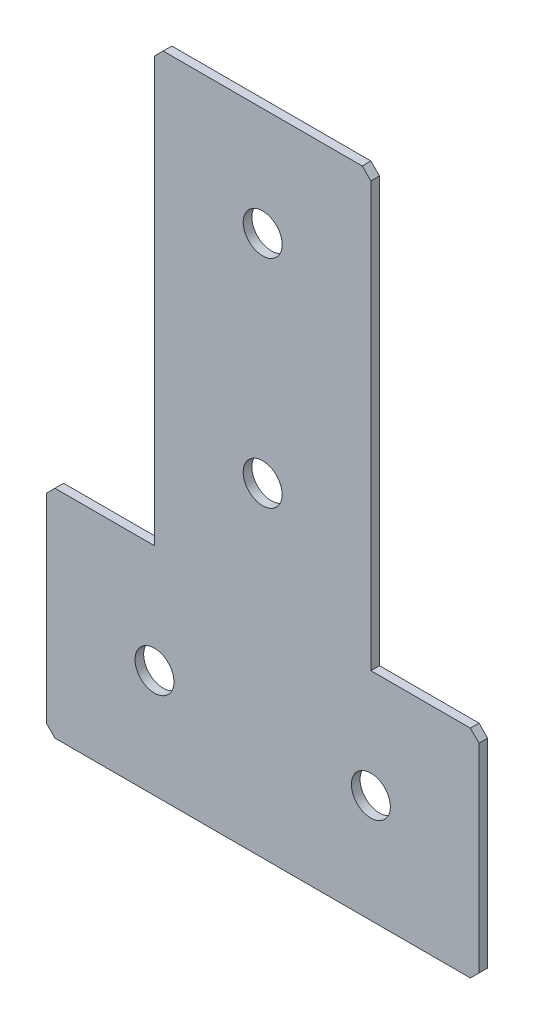
from build123d import *

# Parameters (mm, degrees)
EXTRUDE_1_DEPTH   = 2
HOLE_WIZARD_M81_D = 9
CHAMFER_1_SIZE    = 2


with BuildPart() as part:
    # Эскиз1 → Бобышка-Вытянуть1 (new body)
    with BuildSketch(Plane(origin=(0, 0, 0), x_dir=(1, 0, 0), z_dir=(0, 0, -1))):
        Polygon((-50, 150), (50, 150), (50, 100), (25, 100), (25, 0), (-25, 0), (-25, 100), (-50, 100), align=None)
    extrude(amount=EXTRUDE_1_DEPTH)

    # Отверстие с зазором M81 (through all)
    with Locations(Plane(origin=(0, 0, -2), x_dir=(1, 0, 0), z_dir=(0, 0, -1))):
        with Locations((0, 25), (-25, 125), (25, 125), (0, 75)):
            Hole(HOLE_WIZARD_M81_D / 2)

    # Фаска1
    chamfer_1_edges = [part.edges().sort_by_distance(p)[0] for p in [
        (-50, -100, -1),
        (-50, -150, -1),
        (50, -150, -1),
        (50, -100, -1),
        (25, 0, -1),
        (-25, 0, -1),
    ]]
    chamfer(chamfer_1_edges, length=CHAMFER_1_SIZE)


solid = part.part
